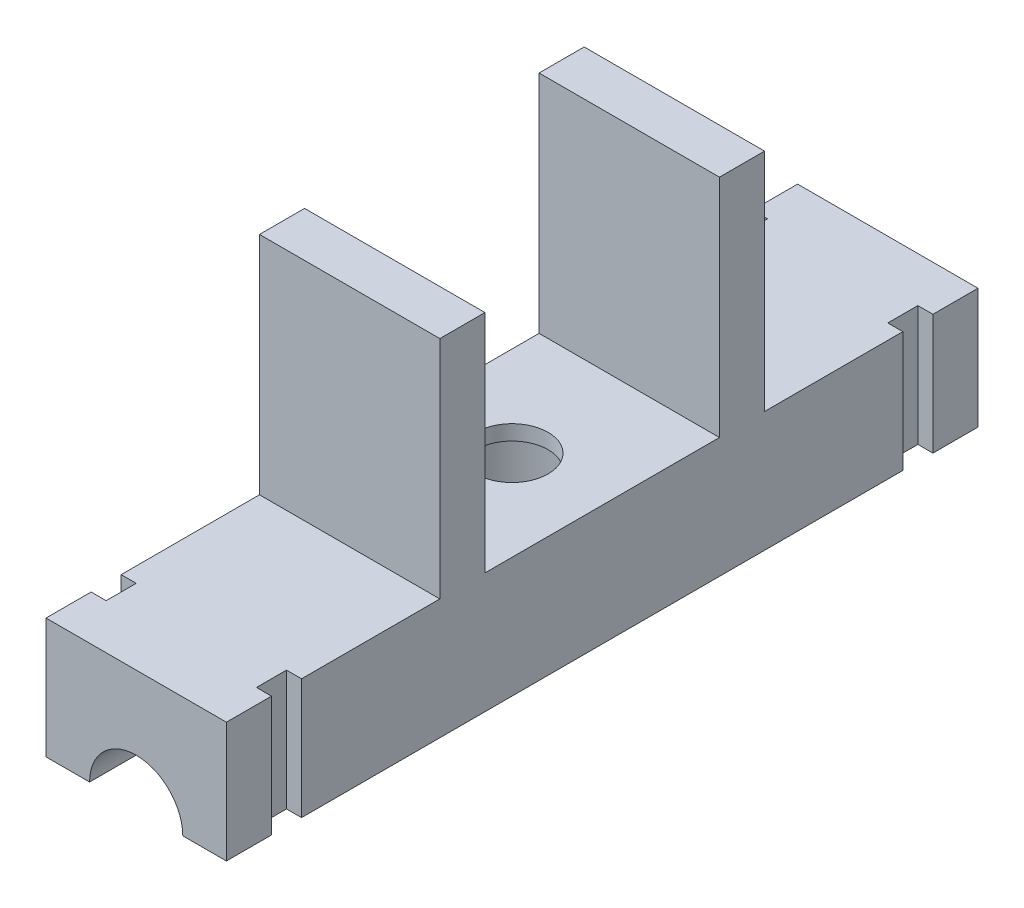
from build123d import *

# Parameters (mm, degrees)
BOSS_EXTRUDE1_DEPTH                              = 12
CBORE_FOR_M4_PAN_HEAD_MACHINE_SCREW1_D           = 4.8
CBORE_FOR_M4_PAN_HEAD_MACHINE_SCREW1_CBORE_D     = 9
CBORE_FOR_M4_PAN_HEAD_MACHINE_SCREW1_CBORE_DEPTH = 7
F_6_0MM_DOWEL_HOLE1_D                            = 6.2
SKETCH13_W                                       = 1
SKETCH13_H                                       = 2
CUT_EXTRUDE1_DEPTH                               = 12


with BuildPart() as part:
    # Sketch4 → Boss-Extrude1 (new body)
    with BuildSketch(Plane(origin=(0, 0, 0), x_dir=(0, 0, -1), z_dir=(1, 0, 0))):
        Polygon((-25, 0), (0, 0), (0, 8), (-7.8, 8), (-7.8, 23), (-10.8, 23), (-10.8, 8), (-25, 8), align=None)
        Polygon((0, 8), (0, 0), (25, 0), (25, 8), (10.8, 8), (10.8, 23), (7.8, 23), (7.8, 8), align=None)
    extrude(amount=BOSS_EXTRUDE1_DEPTH)

    # CBORE for M4 Pan Head Machine Screw1 (through all)
    with Locations(Plane(origin=(0, 0, 0), x_dir=(-1, 0, 0), z_dir=(0, -1, 0))):
        with Locations((-6, 0)):
            CounterBoreHole(CBORE_FOR_M4_PAN_HEAD_MACHINE_SCREW1_D / 2, CBORE_FOR_M4_PAN_HEAD_MACHINE_SCREW1_CBORE_D / 2, CBORE_FOR_M4_PAN_HEAD_MACHINE_SCREW1_CBORE_DEPTH)

    # Ø6.0mm Dowel Hole1 (through all)
    with Locations(Plane.XY.offset(25)):
        with Locations((6, 0)):
            Hole(F_6_0MM_DOWEL_HOLE1_D / 2)

    # Sketch13 → Cut-Extrude1 (cut)
    with BuildSketch(Plane.XZ):
        with Locations((0.5, -21)):
            Rectangle(SKETCH13_W, SKETCH13_H)
        with Locations((0.5, 21)):
            Rectangle(SKETCH13_W, SKETCH13_H)
        with Locations((11.5, 21)):
            Rectangle(SKETCH13_W, SKETCH13_H)
        with Locations((11.5, -21)):
            Rectangle(SKETCH13_W, SKETCH13_H)
    extrude(amount=-CUT_EXTRUDE1_DEPTH, mode=Mode.SUBTRACT)


solid = part.part
